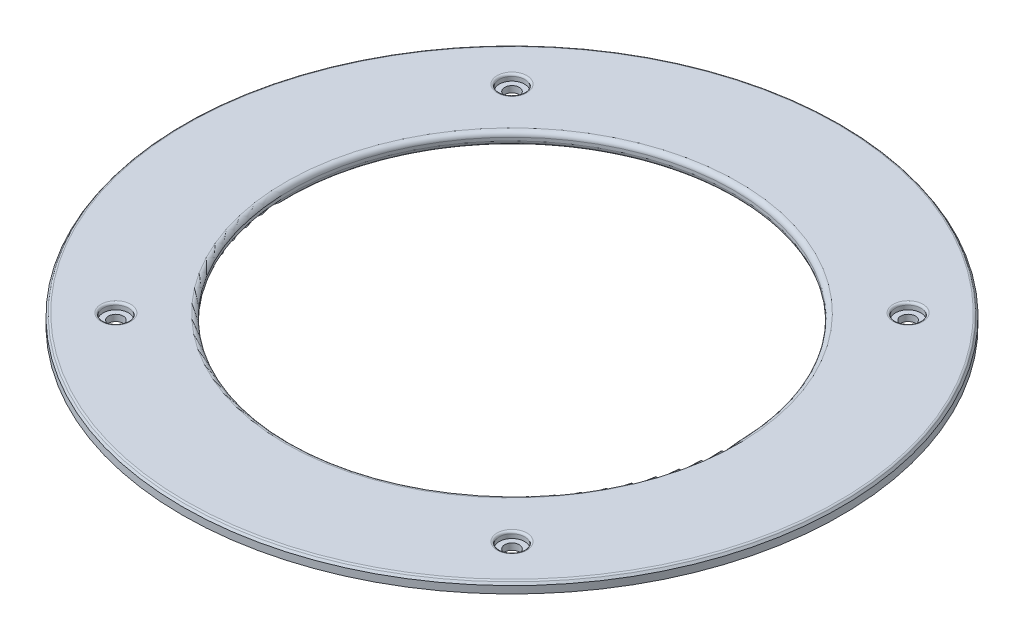
from build123d import *

# Parameters (mm, degrees)
SKETCH2_R                               = 104
BOSS_EXTRUDE3_DEPTH                     = 4
CBORE_FOR_M5_HEX_HEAD_BOLT1_D           = 4.6
CBORE_FOR_M5_HEX_HEAD_BOLT1_CBORE_D     = 8
CBORE_FOR_M5_HEX_HEAD_BOLT1_CBORE_DEPTH = 2
SKETCH7_R                               = 70
CUT_EXTRUDE1_DEPTH                      = 4
FILLET1_R                               = 1.5
CHAMFER1_SIZE                           = 1
CHAMFER1_SIZE2                          = 0.700207538
CHAMFER1_PART_2_SIZE                    = 1
CHAMFER1_PART_2_SIZE2                   = 0.700207538
FILLET2_R                               = 0.7
FILLET3_R                               = 0.7
FILLET4_R                               = 0.7


with BuildPart() as part:
    # Sketch2 → Boss-Extrude3 (new body)
    with BuildSketch(Plane(origin=(0, 0, 0), x_dir=(1, 0, 0), z_dir=(0, 1, 0))):
        Circle(SKETCH2_R)
    extrude(amount=BOSS_EXTRUDE3_DEPTH)

    # CBORE for M5 Hex Head Bolt1 (through all)
    with Locations(Plane(origin=(0, 4, 0), x_dir=(1, 0, 0), z_dir=(0, 1, 0))):
        with Locations((-62.5, 62.5), (62.5, 62.5), (62.5, -62.5), (-62.5, -62.5)):
            CounterBoreHole(CBORE_FOR_M5_HEX_HEAD_BOLT1_D / 2, CBORE_FOR_M5_HEX_HEAD_BOLT1_CBORE_D / 2, CBORE_FOR_M5_HEX_HEAD_BOLT1_CBORE_DEPTH)

    # Sketch7 → Cut-Extrude1 (cut)
    with BuildSketch(Plane(origin=(0, 4, 0), x_dir=(1, 0, 0), z_dir=(0, 1, 0))):
        Circle(SKETCH7_R)
    extrude(amount=-CUT_EXTRUDE1_DEPTH, mode=Mode.SUBTRACT)

    # Fillet1
    fillet1_edges = [part.edges().sort_by_distance(p)[0] for p in [
        (-70, 0, 0),
        (-70, 4, 0),
    ]]
    fillet(fillet1_edges, radius=FILLET1_R)

    # Chamfer1
    chamfer1_edges = [part.edges().sort_by_distance(p)[0] for p in [
        (-104, 0, 0),
    ]]
    chamfer1_side = [part.faces().sort_by_distance(p)[0] for p in [
        (-74.44156421, 0, 0),
    ]]
    chamfer(chamfer1_edges, length=CHAMFER1_SIZE, length2=CHAMFER1_SIZE2, reference=chamfer1_side[0])

    # Chamfer1 part 2
    chamfer1_part_2_edges = [part.edges().sort_by_distance(p)[0] for p in [
        (-104, 4, 0),
    ]]
    chamfer1_part_2_side = [part.faces().sort_by_distance(p)[0] for p in [
        (-104, 2, 0),
    ]]
    chamfer(chamfer1_part_2_edges, length=CHAMFER1_PART_2_SIZE, length2=CHAMFER1_PART_2_SIZE2, reference=chamfer1_part_2_side[0])

    # Fillet2
    fillet2_edges = [part.edges().sort_by_distance(p)[0] for p in [
        (-66.5, 4, 62.5),
        (58.5, 4, 62.5),
        (58.5, 4, -62.5),
        (-66.5, 4, -62.5),
    ]]
    fillet(fillet2_edges, radius=FILLET2_R)

    # Fillet3
    fillet3_edges = [part.edges().sort_by_distance(p)[0] for p in [
        (-103, 0, 0),
    ]]
    fillet(fillet3_edges, radius=FILLET3_R)

    # Fillet4
    fillet4_edges = [part.edges().sort_by_distance(p)[0] for p in [
        (-103.299792462, 4, 0),
    ]]
    fillet(fillet4_edges, radius=FILLET4_R)


solid = part.part
